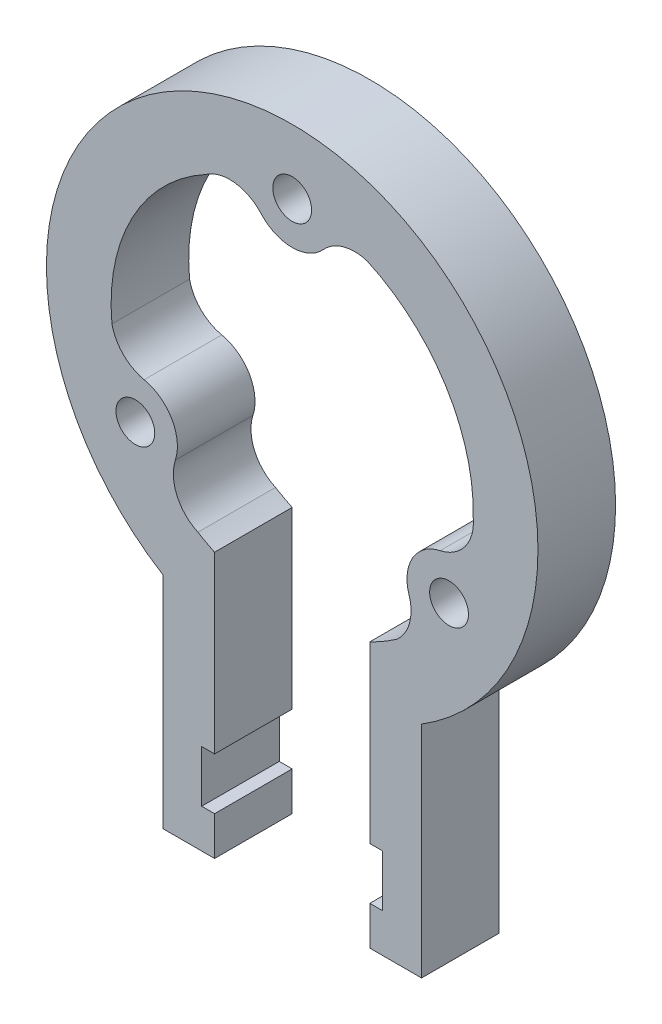
from build123d import *

# Parameters (mm, degrees)
ESQUISSE1_R        = 1.5
BOSS_EXTRU_2_DEPTH = 6


with BuildPart() as part:
    # Esquisse1 → Boss.-Extru.2 (new body)
    with BuildSketch(Plane.XY):
        with BuildLine():
            Line((-6, -33.155494421), (-6, -30.155494421))
            Line((-6, -30.155494421), (-7, -30.155494421))
            Line((-7, -30.155494421), (-7, -26.155494421))
            Line((-7, -26.155494421), (-6, -26.155494421))
            Line((-6, -26.155494421), (-6, -12.649110641))
            ThreePointArc((-6, -12.649110641), (-6.653410863, -12.317959405), (-7.288606081, -11.953084179))
            ThreePointArc((-7.288606081, -11.953084179), (-8.912631465, -10.307392628), (-9.031496673, -7.998360322))
            ThreePointArc((-9.031496673, -7.998360322), (-9.309773091, -5.375), (-11.442531564, -3.822325392))
            ThreePointArc((-11.442531564, -3.822325392), (-13.054716827, -2.946828253), (-13.935938611, -1.337764944))
            ThreePointArc((-13.935938611, -1.337764944), (-12.367555464, 6.560760004), (-6.707371512, 12.288660114))
            ThreePointArc((-6.707371512, 12.288660114), (-4.47014813, 12.872261577), (-2.411034891, 11.820685714))
            ThreePointArc((-2.411034891, 11.820685714), (0, 10.75), (2.411034891, 11.820685714))
            ThreePointArc((2.411034891, 11.820685714), (3.975330286, 12.779130538), (5.80943088, 12.737759334))
            ThreePointArc((5.80943088, 12.737759334), (11.865562564, 7.430237213), (13.995977593, -0.335575935))
            ThreePointArc((13.995977593, -0.335575935), (13.382779595, -2.564868949), (11.442531564, -3.822325392))
            ThreePointArc((11.442531564, -3.822325392), (9.309773091, -5.375), (9.031496673, -7.998360322))
            ThreePointArc((9.031496673, -7.998360322), (9.079386541, -9.832302285), (8.126507731, -11.399994391))
            ThreePointArc((8.126507731, -11.399994391), (7.090812931, -12.071469338), (6, -12.649110641))
            Line((6, -12.649110641), (6, -26.155494421))
            Line((6, -26.155494421), (7, -26.155494421))
            Line((7, -26.155494421), (7, -30.155494421))
            Line((7, -30.155494421), (6, -30.155494421))
            Line((6, -30.155494421), (6, -33.155494421))
            Line((6, -33.155494421), (10, -33.155494421))
            Line((10, -33.155494421), (10, -16.155494421))
            ThreePointArc((10, -16.155494421), (0, 19), (-10, -16.155494421))
            Line((-10, -16.155494421), (-10, -33.155494421))
            Line((-10, -33.155494421), (-6, -33.155494421))
        make_face()
        with Locations((0, 14)):
            Circle(ESQUISSE1_R, mode=Mode.SUBTRACT)
        with Locations((12.124355653, -7)):
            Circle(ESQUISSE1_R, mode=Mode.SUBTRACT)
        with Locations((-12.124355653, -7)):
            Circle(ESQUISSE1_R, mode=Mode.SUBTRACT)
    extrude(amount=BOSS_EXTRU_2_DEPTH)


solid = part.part
